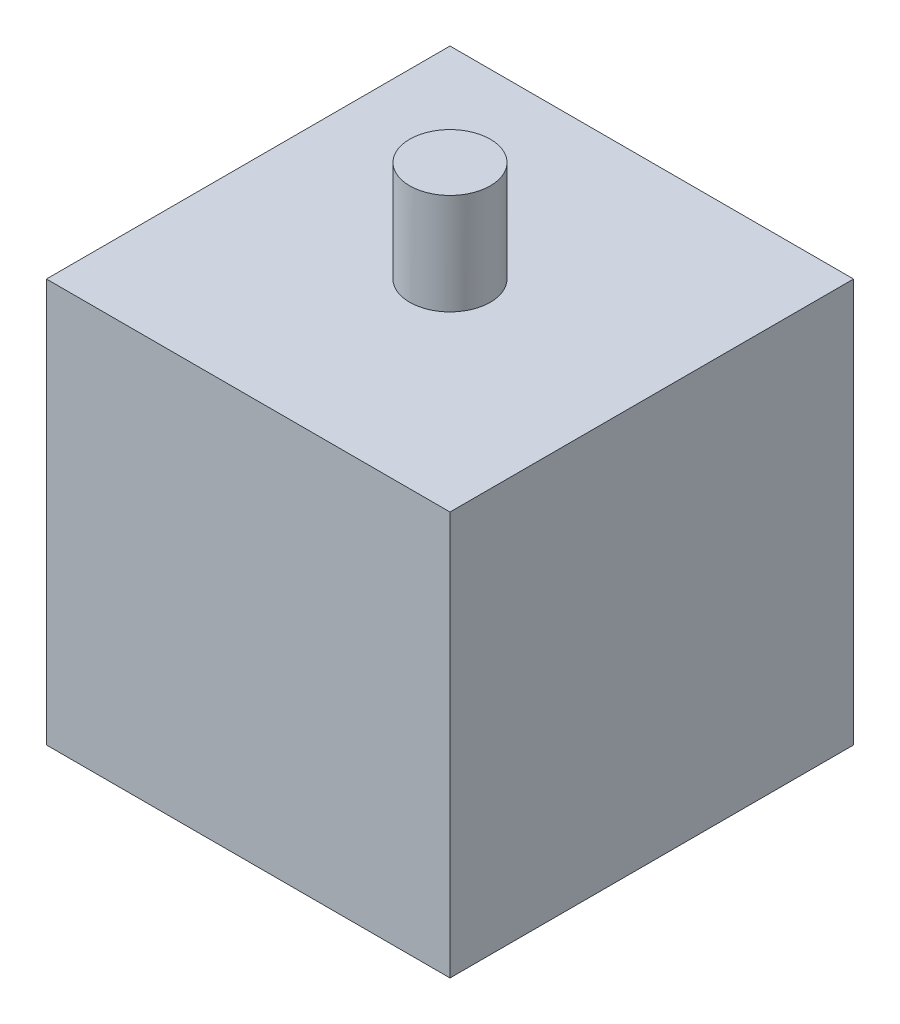
from build123d import *

# Parameters (mm, degrees)
SKETCH1_W           = 100
SKETCH1_H           = 100
BOSS_EXTRUDE1_DEPTH = 100
SKETCH2_R           = 10
BOSS_EXTRUDE2_DEPTH = 25


with BuildPart() as part:
    # Sketch1 → Boss-Extrude1 (new body)
    with BuildSketch(Plane(origin=(0, 0, 0), x_dir=(1, 0, 0), z_dir=(0, 1, 0))):
        with Locations((50, 50)):
            Rectangle(SKETCH1_W, SKETCH1_H)
    extrude(amount=BOSS_EXTRUDE1_DEPTH)

    # Sketch2 → Boss-Extrude2 (add)
    with BuildSketch(Plane(origin=(0, 100, 0), x_dir=(1, 0, 0), z_dir=(0, 1, 0))):
        with Locations((50, 50)):
            Circle(SKETCH2_R)
    extrude(amount=BOSS_EXTRUDE2_DEPTH)


solid = part.part
